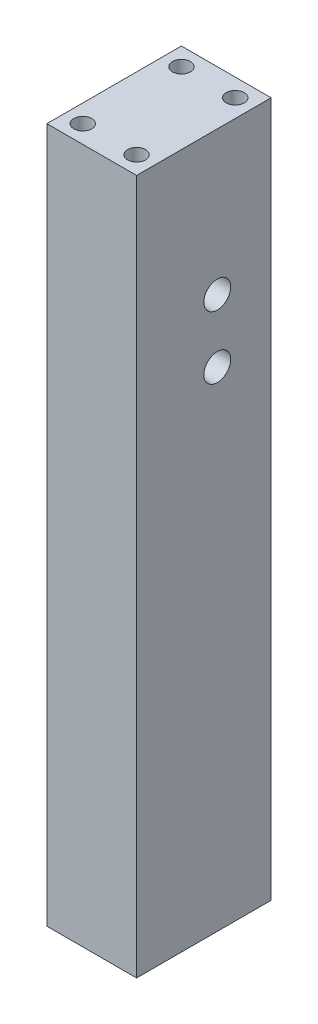
from build123d import *

# Parameters (mm, degrees)
SKETCH1_W           = 15
SKETCH1_H           = 77.5
BOSS_EXTRUDE1_DEPTH = 10
SKETCH3_R           = 1
CUT_EXTRUDE1_DEPTH  = 10
SKETCH4_R           = 1
CUT_EXTRUDE2_DEPTH  = 10
SKETCH5_R           = 1.5
CUT_EXTRUDE3_DEPTH  = 5


with BuildPart() as part:
    # Sketch1 → Boss-Extrude1 (new body)
    with BuildSketch(Plane(origin=(0, 0, 0), x_dir=(0, 0, -1), z_dir=(1, 0, 0))):
        with Locations((7.5, 38.75)):
            Rectangle(SKETCH1_W, SKETCH1_H)
    extrude(amount=BOSS_EXTRUDE1_DEPTH)

    # Sketch3 → Cut-Extrude1 (cut)
    with BuildSketch(Plane(origin=(0, 77.5, 0), x_dir=(1, 0, 0), z_dir=(0, 1, 0))):
        with Locations((2, 13)):
            Circle(SKETCH3_R)
        with Locations((8, 13)):
            Circle(SKETCH3_R)
        with Locations((8, 2)):
            Circle(SKETCH3_R)
        with Locations((2, 2)):
            Circle(SKETCH3_R)
    extrude(amount=-CUT_EXTRUDE1_DEPTH, mode=Mode.SUBTRACT)

    # Sketch4 → Cut-Extrude2 (cut)
    with BuildSketch(Plane(origin=(0, 0, 0), x_dir=(-1, 0, 0), z_dir=(0, -1, 0))):
        with Locations((-8, 2)):
            Circle(SKETCH4_R)
        with Locations((-8, 13)):
            Circle(SKETCH4_R)
        with Locations((-2, 13)):
            Circle(SKETCH4_R)
        with Locations((-2, 2)):
            Circle(SKETCH4_R)
    extrude(amount=-CUT_EXTRUDE2_DEPTH, mode=Mode.SUBTRACT)

    # Sketch5 → Cut-Extrude3 (cut)
    with BuildSketch(Plane(origin=(10, 0, 0), x_dir=(0, 0, -1), z_dir=(1, 0, 0))):
        with Locations((9, 61.5)):
            Circle(SKETCH5_R)
        with Locations((9, 54.5)):
            Circle(SKETCH5_R)
    extrude(amount=-CUT_EXTRUDE3_DEPTH, mode=Mode.SUBTRACT)


solid = part.part
